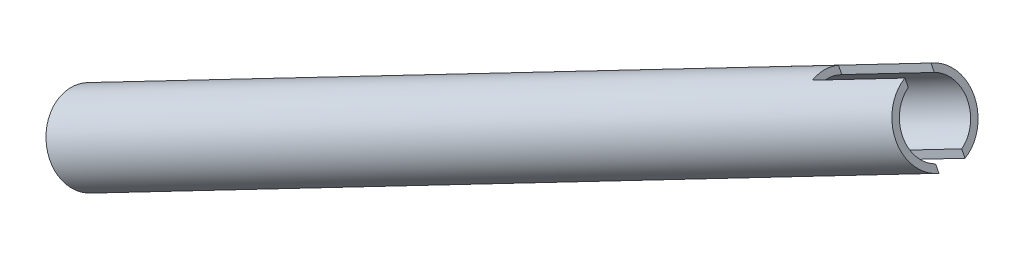
from build123d import *

# Parameters (mm, degrees)
CUT_EXTRUDE1_START = -25.4
SKETCH2_W          = 6.35
SKETCH2_H          = 19.05
CUT_EXTRUDE1_DEPTH = 25.4


with BuildPart() as part:
    # Sketch1 → Revolve1 (revolve)
    with BuildSketch(Plane.XY):
        Polygon((528.662376284, -1604.36232837), (529.424259242, -1605.827024707), (323.502507791, -1712.940198389), (322.740624833, -1711.475502052), align=None)
    revolve(axis=Axis((319.107029188, -1704.490027216, 0), (0.887157078, 0.46146757, 0)))

    # Sketch2 → Cut-Extrude1 (cut)
    with BuildSketch(Plane(origin=(-240.734168067, -125.221355071, 0), x_dir=(0, 0, -1), z_dir=(0.887157078, 0.46146757, 0)).offset(CUT_EXTRUDE1_START)):
        with Locations((0, -1659.407938171)):
            Rectangle(SKETCH2_W, SKETCH2_H)
    extrude(amount=CUT_EXTRUDE1_DEPTH, mode=Mode.SUBTRACT)


solid = part.part
